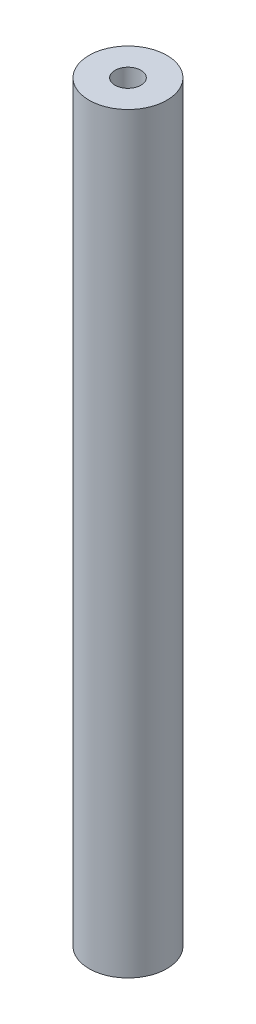
from build123d import *

# Parameters (mm, degrees)
SKETCH1_R           = 1.5
SKETCH1_R_2         = 0.5
BOSS_EXTRUDE1_DEPTH = 29


with BuildPart() as part:
    # Sketch1 → Boss-Extrude1 (new body)
    with BuildSketch(Plane(origin=(0, 0, 0), x_dir=(1, 0, 0), z_dir=(0, 1, 0))):
        Circle(SKETCH1_R)
        Circle(SKETCH1_R_2, mode=Mode.SUBTRACT)
    extrude(amount=BOSS_EXTRUDE1_DEPTH)


solid = part.part
